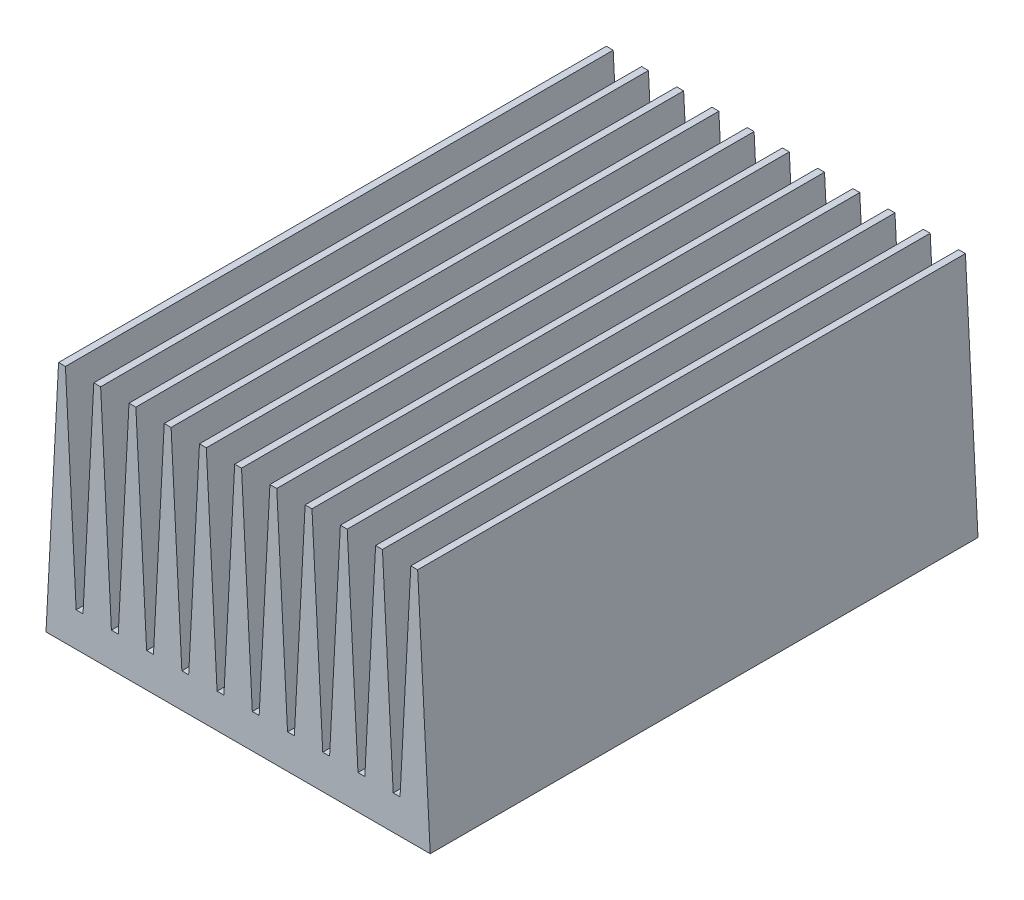
from build123d import *

# Parameters (mm, degrees)
BOSS_EXTRUDE1_DEPTH = 80


with BuildPart() as part:
    # Sketch1 → Boss-Extrude1 (new body)
    with BuildSketch(Plane.XY):
        Polygon((-24.257476664, 0), (0, 0), (13.70186971, 0), (11.867597435, 35), (10.867597435, 35), (9.295364057, 5), (8.295364057, 5), (6.723130678, 35), (5.723130678, 35), (4.1508973, 5), (3.150897297, 5), (1.578663918, 35), (0.578663918, 35), (-0.99356946, 5), (-1.993569463, 5), (-3.565802842, 35), (-4.565802842, 35), (-6.13803622, 5), (-7.138036223, 5), (-8.710269602, 35), (-9.710269602, 35), (-11.28250298, 5), (-12.282502983, 5), (-13.854736362, 35), (-14.854736362, 35), (-16.42696974, 5), (-17.426969743, 5), (-18.999203122, 35), (-19.999203122, 35), (-21.5714365, 5), (-22.571436503, 5), (-24.143669882, 35), (-25.143669882, 35), (-26.71590326, 5), (-27.715903263, 5), (-29.288136642, 35), (-30.288136642, 35), (-31.86037002, 5), (-32.860370023, 5), (-34.432603402, 35), (-35.432603402, 35), (-37.00483678, 5), (-38.004836783, 5), (-39.577070162, 35), (-40.577070162, 35), (-42.14930354, 5), (-42.411342437, 0), align=None)
    extrude(amount=BOSS_EXTRUDE1_DEPTH)


solid = part.part
